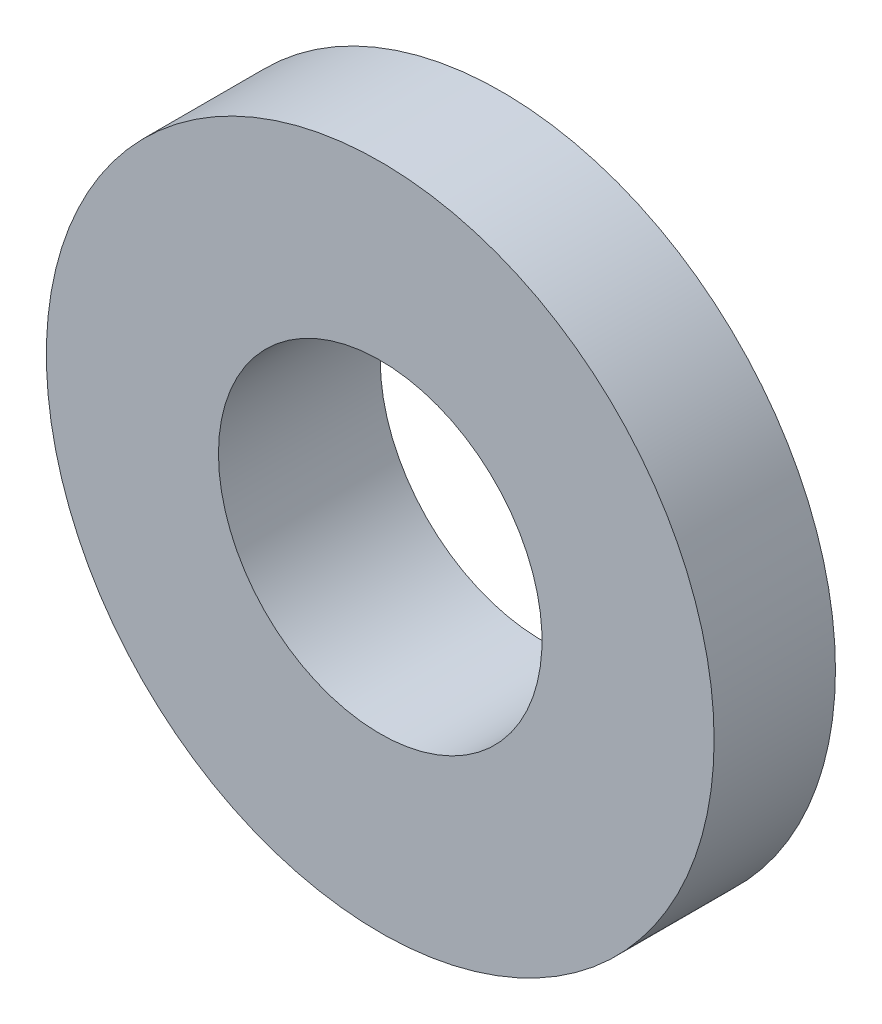
from build123d import *

# Parameters (mm, degrees)
SKETCH1_R           = 8.255
BOSS_EXTRUDE1_DEPTH = 3
SKETCH2_R           = 5
BOSS_EXTRUDE2_DEPTH = 1
SKETCH3_R           = 4
CUT_EXTRUDE1_DEPTH  = 5


with BuildPart() as part:
    # Sketch1 → Boss-Extrude1 (new body)
    with BuildSketch(Plane.XY):
        Circle(SKETCH1_R)
    extrude(amount=BOSS_EXTRUDE1_DEPTH)

    # Sketch2 → Boss-Extrude2 (add)
    with BuildSketch(Plane(origin=(0, 0, 0), x_dir=(-1, 0, 0), z_dir=(0, 0, -1))):
        Circle(SKETCH2_R)
    extrude(amount=BOSS_EXTRUDE2_DEPTH)

    # Sketch3 → Cut-Extrude1 (cut, through all)
    with BuildSketch(Plane(origin=(0, 0, -1), x_dir=(-1, 0, 0), z_dir=(0, 0, -1))):
        Circle(SKETCH3_R)
    extrude(amount=-CUT_EXTRUDE1_DEPTH, mode=Mode.SUBTRACT)


solid = part.part
